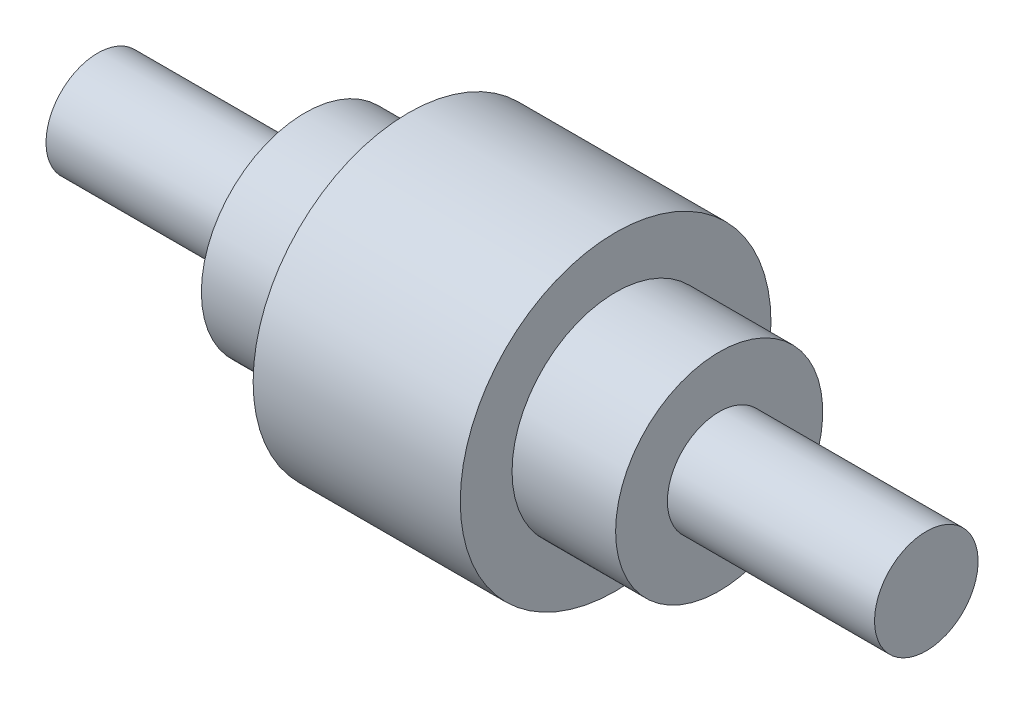
from build123d import *


with BuildPart() as part:
    # Sketch2 → Revolve-Thin2 (revolve)
    with BuildSketch(Plane.XY, mode=Mode.PRIVATE) as revolve_thin2_sk:
        Polygon((-150, 0), (-150, 10), (-70, 10), (-70, 30), (-30, 30), (-30, 50), (30, 50), (30, 30), (70, 30), (70, 10), (150, 10), (150, 0), (160, 0), (160, 20), (80, 20), (80, 40), (40, 40), (40, 60), (-40, 60), (-40, 40), (-80, 40), (-80, 20), (-160, 20), (-160, 0), align=None)
    revolve(revolve_thin2_sk.sketch.rotate(Axis((-150, 0, 0), (1, 0, 0)), 90), axis=Axis((-150, 0, 0), (1, 0, 0)))  # turned: the seam where the file's is


solid = part.part
